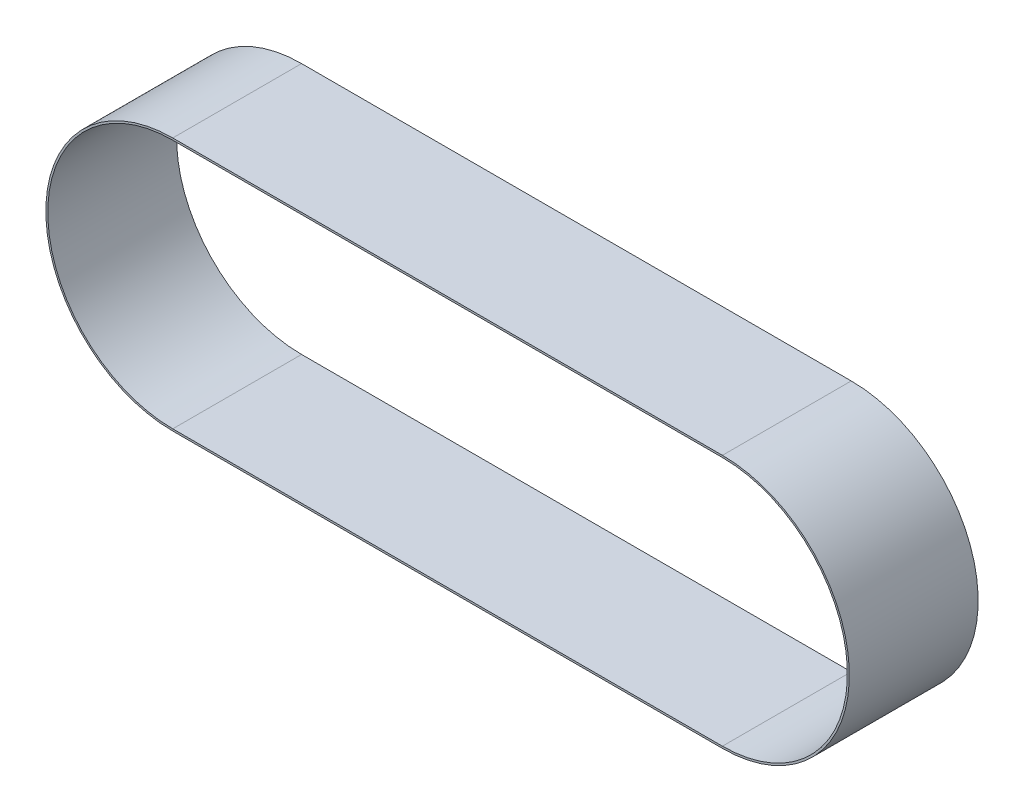
from build123d import *

# Parameters (mm, degrees)
BOSS_EXTRUDE1_DEPTH = 30


with BuildPart() as part:
    # Sketch1 → Boss-Extrude1 (new body)
    with BuildSketch(Plane.XY):
        with BuildLine():
            ThreePointArc((0, 29.555), (-29.555, 0), (0, -29.555))
            Line((0, -29.555), (128, -29.555))
            ThreePointArc((128, -29.555), (157.555, 0), (128, 29.555))
            Line((128, 29.555), (0, 29.555))
        make_face()
        with BuildLine():
            ThreePointArc((0, -29.105), (-29.105, 0), (0, 29.105))
            Line((0, 29.105), (128, 29.105))
            ThreePointArc((128, 29.105), (157.105, 0), (128, -29.105))
            Line((128, -29.105), (0, -29.105))
        make_face(mode=Mode.SUBTRACT)
    extrude(amount=BOSS_EXTRUDE1_DEPTH)


solid = part.part
